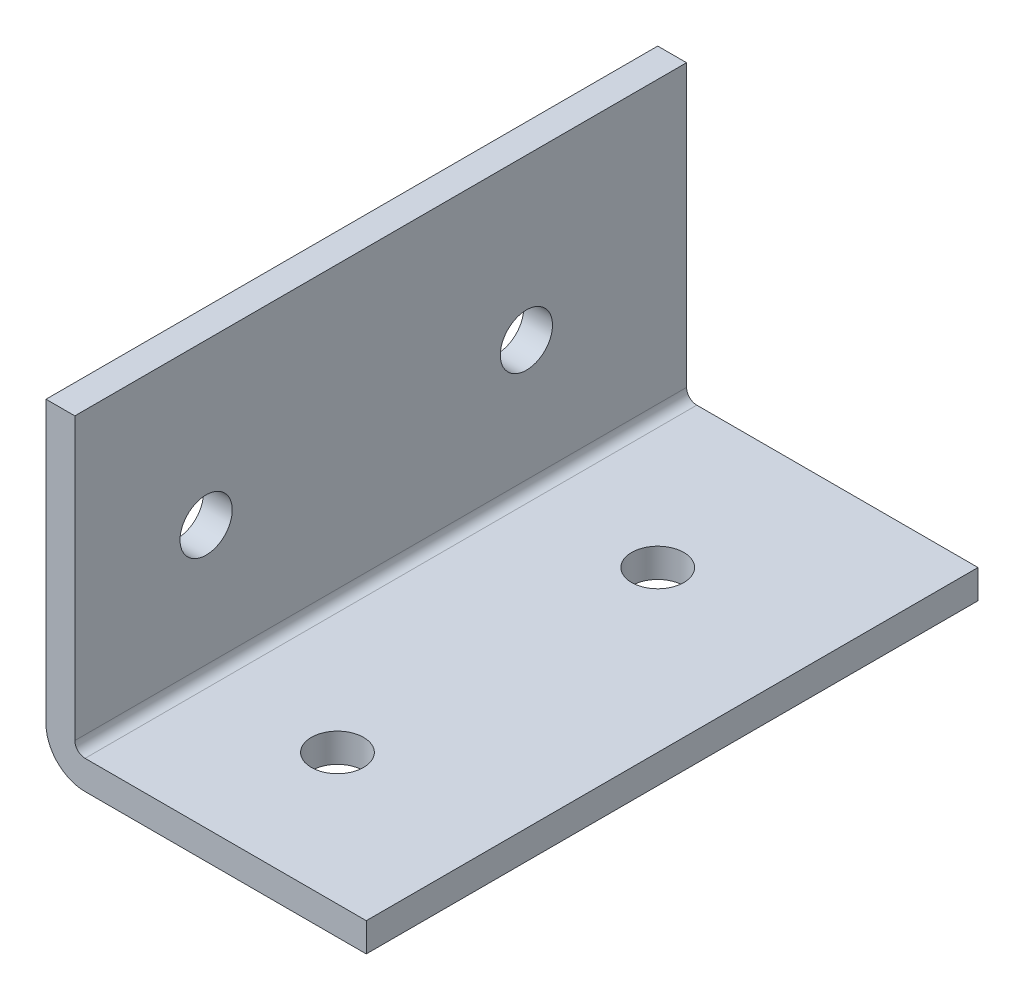
from build123d import *

# Parameters (mm, degrees)
SKETCH1_W                  = 25.4
SKETCH1_H                  = 1498.6
BOSS_EXTRUDE1_DEPTH        = 25.4
SKETCH2_W                  = 23.114
SKETCH2_H                  = 23.114
CUT_EXTRUDE1_DEPTH         = 1499.6
M3_5_CLEARANCE_HOLE1_D     = 4.1402
M3_5_CLEARANCE_HOLE1_DEPTH = 25.4
M3_5_CLEARANCE_HOLE2_D     = 4.1402
M3_5_CLEARANCE_HOLE2_DEPTH = 25.4
CHAMFER1_SIZE              = 2.159
FILLET1_R                  = 0.8128
FILLET2_R                  = 3.0988
SKETCH8_W                  = 95.882963774
SKETCH8_H                  = 79.338329604
CUT_EXTRUDE3_DEPTH         = 1371.6
SKETCH9_W                  = 56.924523055
SKETCH9_H                  = 51.282783217
CUT_EXTRUDE4_DEPTH         = 76.2
SKETCH11_W                 = 51.462522779
SKETCH11_H                 = 66.676735099
CUT_EXTRUDE6_DEPTH         = 2.286


with BuildPart() as part:
    # Sketch1 → Boss-Extrude1 (new body)
    with BuildSketch(Plane(origin=(0, 0, 0), x_dir=(0, -1, 0), z_dir=(-1, 0, 0))):
        with Locations((-12.7, 0)):
            Rectangle(SKETCH1_W, SKETCH1_H)
    extrude(amount=-BOSS_EXTRUDE1_DEPTH)

    # Sketch2 → Cut-Extrude1 (cut, through all)
    with BuildSketch(Plane(origin=(0, 0, -749.3), x_dir=(-1, 0, 0), z_dir=(0, 0, -1))):
        with Locations((-13.843, 13.843)):
            Rectangle(SKETCH2_W, SKETCH2_H)
    extrude(amount=-CUT_EXTRUDE1_DEPTH, mode=Mode.SUBTRACT)

    # M3.5 Clearance Hole1
    with Locations(Plane(origin=(0, 0, 0), x_dir=(-1, 0, 0), z_dir=(0, -1, 0))):
        with Locations((-12.7, 736.6), (-12.7, 711.2), (-12.7, 685.8), (-12.7, 660.4), (-12.7, 635), (-12.7, 609.6), (-12.7, 584.2), (-12.7, 558.8), (-12.7, 533.4), (-12.7, 508), (-12.7, 482.6), (-12.7, 457.2), (-12.7, 431.8), (-12.7, 406.4), (-12.7, 381), (-12.7, 355.6), (-12.7, 330.2), (-12.7, 304.8), (-12.7, 279.4), (-12.7, 254), (-12.7, 228.6), (-12.7, 203.2), (-12.7, 177.8), (-12.7, 152.4), (-12.7, 127), (-12.7, 101.6), (-12.7, 76.2), (-12.7, 50.8), (-12.7, 25.4), (-12.7, 0), (-12.7, -25.4), (-12.7, -50.8), (-12.7, -76.2), (-12.7, -101.6), (-12.7, -127), (-12.7, -152.4), (-12.7, -177.8), (-12.7, -203.2), (-12.7, -228.6), (-12.7, -254), (-12.7, -279.4), (-12.7, -304.8), (-12.7, -330.2), (-12.7, -355.6), (-12.7, -381), (-12.7, -406.4), (-12.7, -431.8), (-12.7, -457.2), (-12.7, -482.6), (-12.7, -508), (-12.7, -533.4), (-12.7, -558.8), (-12.7, -584.2), (-12.7, -609.6), (-12.7, -635), (-12.7, -660.4), (-12.7, -685.8), (-12.7, -711.2), (-12.7, -736.6)):
            Hole(M3_5_CLEARANCE_HOLE1_D / 2, depth=M3_5_CLEARANCE_HOLE1_DEPTH)

    # M3.5 Clearance Hole2
    with Locations(Plane.ZY):
        with Locations((711.2, 12.7), (736.6, 12.7), (685.8, 12.7), (660.4, 12.7), (635, 12.7), (609.6, 12.7), (584.2, 12.7), (558.8, 12.7), (533.4, 12.7), (508, 12.7), (482.6, 12.7), (457.2, 12.7), (431.8, 12.7), (406.4, 12.7), (381, 12.7), (355.6, 12.7), (330.2, 12.7), (304.8, 12.7), (279.4, 12.7), (254, 12.7), (228.6, 12.7), (203.2, 12.7), (177.8, 12.7), (152.4, 12.7), (127, 12.7), (101.6, 12.7), (76.2, 12.7), (50.8, 12.7), (25.4, 12.7), (0, 12.7), (-25.4, 12.7), (-50.8, 12.7), (-76.2, 12.7), (-101.6, 12.7), (-127, 12.7), (-152.4, 12.7), (-177.8, 12.7), (-203.2, 12.7), (-228.6, 12.7), (-254, 12.7), (-279.4, 12.7), (-304.8, 12.7), (-330.2, 12.7), (-355.6, 12.7), (-381, 12.7), (-406.4, 12.7), (-431.8, 12.7), (-457.2, 12.7), (-482.6, 12.7), (-508, 12.7), (-533.4, 12.7), (-558.8, 12.7), (-584.2, 12.7), (-609.6, 12.7), (-635, 12.7), (-660.4, 12.7), (-685.8, 12.7), (-711.2, 12.7), (-736.6, 12.7)):
            Hole(M3_5_CLEARANCE_HOLE2_D / 2, depth=M3_5_CLEARANCE_HOLE2_DEPTH)

    # Chamfer1
    chamfer1_edges = [part.edges().sort_by_distance(p)[0] for p in [
        (25.4, 1.143, -749.3),
        (1.143, 25.4, 749.3),
        (1.143, 25.4, -749.3),
        (25.4, 1.143, 749.3),
    ]]
    chamfer(chamfer1_edges, length=CHAMFER1_SIZE)

    # Fillet1
    fillet1_edges = [part.edges().sort_by_distance(p)[0] for p in [
        (2.286, 2.286, 0),
    ]]
    fillet(fillet1_edges, radius=FILLET1_R)

    # Fillet2
    fillet2_edges = [part.edges().sort_by_distance(p)[0] for p in [
        (0, 0, 0),
    ]]
    fillet(fillet2_edges, radius=FILLET2_R)

    # Sketch8 → Cut-Extrude3 (cut)
    with BuildSketch(Plane.XY.offset(749.3)):
        with Locations((2.286, 3.0988)):
            Rectangle(SKETCH8_W, SKETCH8_H)
    extrude(amount=-CUT_EXTRUDE3_DEPTH, mode=Mode.SUBTRACT)

    # Sketch9 → Cut-Extrude4 (cut)
    with BuildSketch(Plane(origin=(0, 0, -749.3), x_dir=(-1, 0, 0), z_dir=(0, 0, -1))):
        with Locations((-2.180776643, 1.30746368)):
            Rectangle(SKETCH9_W, SKETCH9_H)
    extrude(amount=-CUT_EXTRUDE4_DEPTH, mode=Mode.SUBTRACT)

    # Sketch11 → Cut-Extrude6 (cut)
    with BuildSketch(Plane.XY.offset(-622.3)):
        with Locations((1.85517497, 1.74884985)):
            Rectangle(SKETCH11_W, SKETCH11_H)
    extrude(amount=-CUT_EXTRUDE6_DEPTH, mode=Mode.SUBTRACT)


solid = part.part
